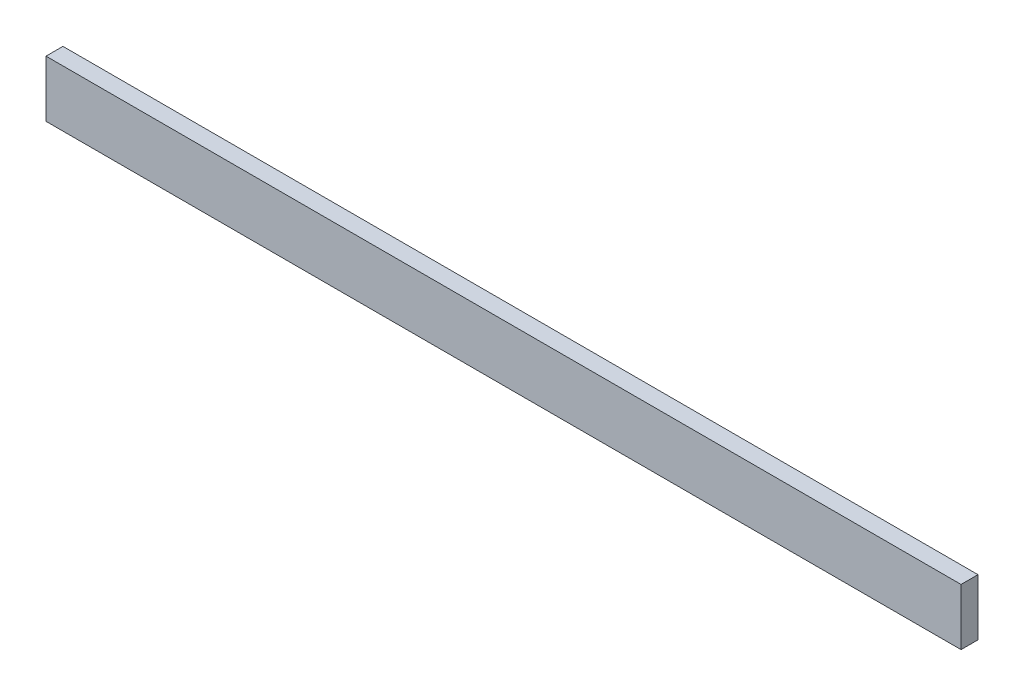
from build123d import *

# Parameters (mm, degrees)
BOSS_EXTRUDE1_DEPTH      = 514.35
BOSS_EXTRUDE1_DEPTH_BACK = 514.35
SKETCH1_W                = 19.05
SKETCH1_H                = 63.5


with BuildPart() as part:
    # Sketch1 → Boss-Extrude1 (new, two sides: drawn at the far end of the back side and taken through both)
    with BuildSketch(Plane(origin=(0, 0, 0), x_dir=(0, 0, -1), z_dir=(1, 0, 0)).offset(-BOSS_EXTRUDE1_DEPTH_BACK)):
        Rectangle(SKETCH1_W, SKETCH1_H)
    extrude(amount=BOSS_EXTRUDE1_DEPTH + BOSS_EXTRUDE1_DEPTH_BACK)


solid = part.part
